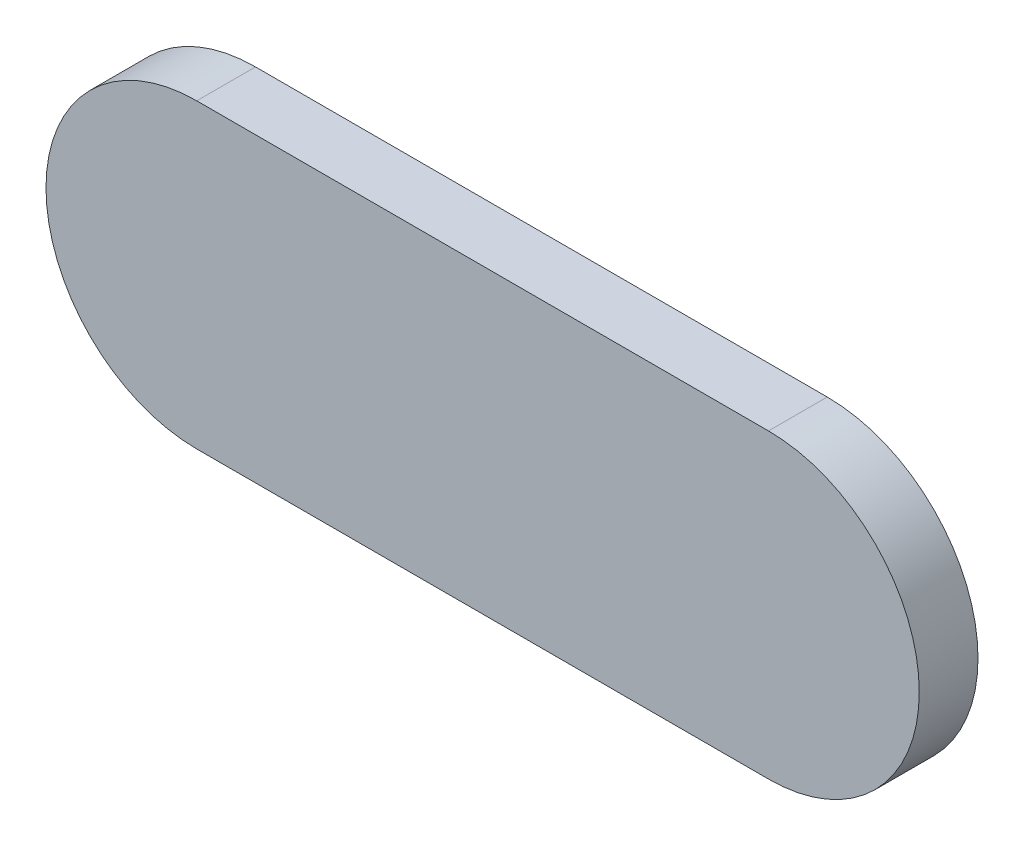
from build123d import *

# Parameters (mm, degrees)
EXTRUDE_1_DEPTH = 1.5
EXTRUDE_2_DEPTH = 0.5
SKETCH_3_R      = 0.75
EXTRUDE_3_DEPTH = 1
FILLET_2_R      = 0.5


with BuildPart() as part:
    # 草图1 → 凸台-拉伸1 (new body)
    with BuildSketch(Plane.XY):
        with BuildLine():
            Line((7.3, 3.85), (-7.3, 3.85))
            ThreePointArc((-7.3, 3.85), (-11.15, 0), (-7.3, -3.85))
            Line((-7.3, -3.85), (7.3, -3.85))
            ThreePointArc((7.3, -3.85), (11.15, 0), (7.3, 3.85))
        make_face()
    extrude(amount=EXTRUDE_1_DEPTH)

    # 草图2 → 凸台-拉伸2 (add)
    with BuildSketch(Plane(origin=(0, 0, 0), x_dir=(-1, 0, 0), z_dir=(0, 0, -1))):
        with BuildLine():
            Line((-7.35, 2.3), (7.35, 2.3))
            ThreePointArc((7.35, 2.3), (9.65, 0), (7.35, -2.3))
            Line((7.35, -2.3), (-7.35, -2.3))
            ThreePointArc((-7.35, -2.3), (-9.65, 0), (-7.35, 2.3))
        make_face()
    extrude(amount=EXTRUDE_2_DEPTH)

    # 草图3 → 凸台-拉伸3 (add)
    with BuildSketch(Plane(origin=(0, 0, -0.5), x_dir=(-1, 0, 0), z_dir=(0, 0, -1))):
        with Locations((1.27, 0)):
            Circle(SKETCH_3_R)
        with Locations((3.81, 0)):
            Circle(SKETCH_3_R)
        with Locations((-3.81, 0)):
            Circle(SKETCH_3_R)
        with Locations((-1.27, 0)):
            Circle(SKETCH_3_R)
    extrude(amount=EXTRUDE_3_DEPTH)

    # 圆角2
    fillet_2_edges = [part.edges().sort_by_distance(p)[0] for p in [
        (-0.52, 0, -1.5),
        (-3.06, 0, -1.5),
        (4.56, 0, -1.5),
        (2.02, 0, -1.5),
    ]]
    fillet(fillet_2_edges, radius=FILLET_2_R)


solid = part.part
